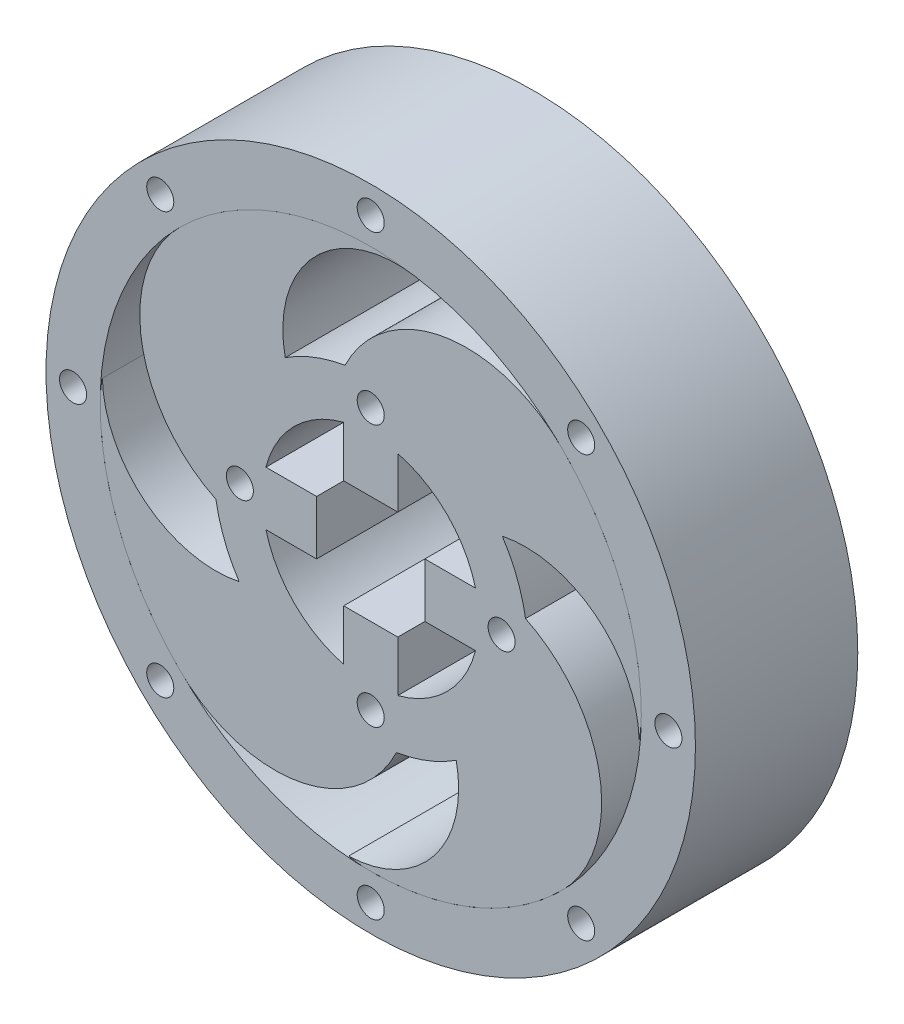
from build123d import *

# Parameters (mm, degrees)
SKETCH6_R                 = 29
SKETCH6_R_2               = 20
INNER_RING_DEPTH          = 30
MOTOR_CONNECTOR_CUT_DEPTH = 30
SKETCH8_R                 = 2.5
M3_HOLES_DEPTH            = 38
M3_HOLES_DEPTH_BACK       = 100
MIDDLE_PATTERN_DEPTH      = 30
SKETCH9_R                 = 60
SKETCH9_R_2               = 50
SKETCH9_R_3               = 2.5
BOSS_EXTRUDE1_DEPTH       = 30


with BuildPart() as part:
    # Sketch6 → Inner Ring (new body)
    with BuildSketch(Plane.XY):
        Circle(SKETCH6_R)
        Circle(SKETCH6_R_2, mode=Mode.SUBTRACT)
    extrude(amount=-INNER_RING_DEPTH)

    # Sketch7 → Motor Connector Cut (add)
    with BuildSketch(Plane.XY):
        with BuildLine():
            ThreePointArc((20, 0), (19.840593925, 2.52008585), (19.364916731, 5))
            Line((19.364916731, 5), (9.999996731, 5))
            Line((9.999996731, 5), (9.999996731, -5))
            Line((9.999996731, -5), (19.364916731, -5))
            ThreePointArc((19.364916731, -5), (19.840593925, -2.52008585), (20, 0))
        make_face()
        with BuildLine():
            ThreePointArc((5, 19.364916731), (0, 20), (-5, 19.364916731))
            Line((-5, 19.364916731), (-5, 9.999996731))
            Line((-5, 9.999996731), (5, 9.999996731))
            Line((5, 9.999996731), (5, 19.364916731))
        make_face()
        with BuildLine():
            Line((-9.999996731, -5), (-9.999996731, 5))
            Line((-9.999996731, 5), (-19.364916731, 5))
            ThreePointArc((-19.364916731, 5), (-20, 0), (-19.364916731, -5))
            Line((-19.364916731, -5), (-9.999996731, -5))
        make_face()
        with BuildLine():
            Line((-5, -9.999996731), (-5, -19.364916731))
            ThreePointArc((-5, -19.364916731), (0, -20), (5, -19.364916731))
            Line((5, -19.364916731), (5, -9.999996731))
            Line((5, -9.999996731), (-5, -9.999996731))
        make_face()
    extrude(amount=-MOTOR_CONNECTOR_CUT_DEPTH)

    # Sketch8 → M3 Holes (cut, two sides)
    with BuildSketch(Plane.XY) as m3_holes_sk:
        with Locations((0, 24.182458366)):
            Circle(SKETCH8_R)
        with Locations((24.182458366, 0)):
            Circle(SKETCH8_R)
        with Locations((0, -24.182458366)):
            Circle(SKETCH8_R)
        with Locations((-24.182458366, 0)):
            Circle(SKETCH8_R)
    extrude(amount=M3_HOLES_DEPTH, mode=Mode.SUBTRACT)
    extrude(m3_holes_sk.sketch, amount=-M3_HOLES_DEPTH_BACK, mode=Mode.SUBTRACT)

    # Sketch10 → Middle Pattern (add)
    with BuildSketch(Plane.XY):
        with BuildLine():
            ThreePointArc((28.607215414, 4.756808408), (26.539406056, -11.690163651), (15.800414568, -24.317625284))
            ThreePointArc((15.800414568, -24.317625284), (11.745224483, -41.595013937), (-4.095362954, -49.596795923))
            ThreePointArc((-4.095362954, -49.596795923), (-2.057581903, -49.898955876), (-2.31e-07, -50))
            ThreePointArc((-2.31e-07, -50), (19.134171511, -46.19397667), (35.355339059, -35.355339059))
            ThreePointArc((35.355339059, -35.355339059), (42.321804958, -13.559663633), (28.607215414, 4.756808408))
        make_face()
        with BuildLine():
            ThreePointArc((24.317625284, 15.800414568), (41.595013937, 11.745224483), (49.596795923, -4.095362954))
            ThreePointArc((49.596795923, -4.095362954), (49.898955887, -2.057581788), (50, 0))
            ThreePointArc((50, 0), (46.193976626, 19.134171618), (35.355339059, 35.355339059))
            ThreePointArc((35.355339059, 35.355339059), (13.559663633, 42.321804958), (-4.756808408, 28.607215414))
            ThreePointArc((-4.756808408, 28.607215414), (11.690163651, 26.539406056), (24.317625284, 15.800414568))
        make_face()
        with BuildLine():
            ThreePointArc((8.201394106, 49.322785148), (-15.267827902, 47.611904301), (-35.355339044, 35.355339075))
            ThreePointArc((-35.355339044, 35.355339075), (-42.32180496, 13.559663644), (-28.607215414, -4.756808408))
            ThreePointArc((-28.607215414, -4.756808408), (-26.539406056, 11.690163651), (-15.800414568, 24.317625284))
            ThreePointArc((-15.800414568, 24.317625284), (-10.393277189, 43.149392225), (8.201394106, 49.322785148))
        make_face()
        with BuildLine():
            ThreePointArc((4.756808408, -28.607215414), (-11.690163651, -26.539406056), (-24.317625284, -15.800414568))
            ThreePointArc((-24.317625284, -15.800414568), (-41.595013937, -11.745224483), (-49.596795923, 4.095362954))
            ThreePointArc((-49.596795923, 4.095362954), (-49.898955887, 2.057581788), (-50, 0))
            ThreePointArc((-50, 0), (-46.193976566, -19.134171762), (-35.355338839, -35.35533928))
            ThreePointArc((-35.355338839, -35.35533928), (-13.559663479, -42.321804932), (4.756808408, -28.607215414))
        make_face()
    extrude(amount=-MIDDLE_PATTERN_DEPTH)


with BuildPart() as body_2:
    # Sketch9 → Boss-Extrude1 (new body)
    with BuildSketch(Plane.XY):
        Circle(SKETCH9_R)
        Circle(SKETCH9_R_2, mode=Mode.SUBTRACT)
        with Locations((0, 55)):
            Circle(SKETCH9_R_3, mode=Mode.SUBTRACT)
        with Locations((-38.890872965, 38.890872965)):
            Circle(SKETCH9_R_3, mode=Mode.SUBTRACT)
        with Locations((-55, 0)):
            Circle(SKETCH9_R_3, mode=Mode.SUBTRACT)
        with Locations((-38.890872965, -38.890872965)):
            Circle(SKETCH9_R_3, mode=Mode.SUBTRACT)
        with Locations((0, -55)):
            Circle(SKETCH9_R_3, mode=Mode.SUBTRACT)
        with Locations((38.890872965, -38.890872965)):
            Circle(SKETCH9_R_3, mode=Mode.SUBTRACT)
        with Locations((55, 0)):
            Circle(SKETCH9_R_3, mode=Mode.SUBTRACT)
        with Locations((38.890872965, 38.890872965)):
            Circle(SKETCH9_R_3, mode=Mode.SUBTRACT)
    extrude(amount=-BOSS_EXTRUDE1_DEPTH)


solid = Compound([part.part, body_2.part])
